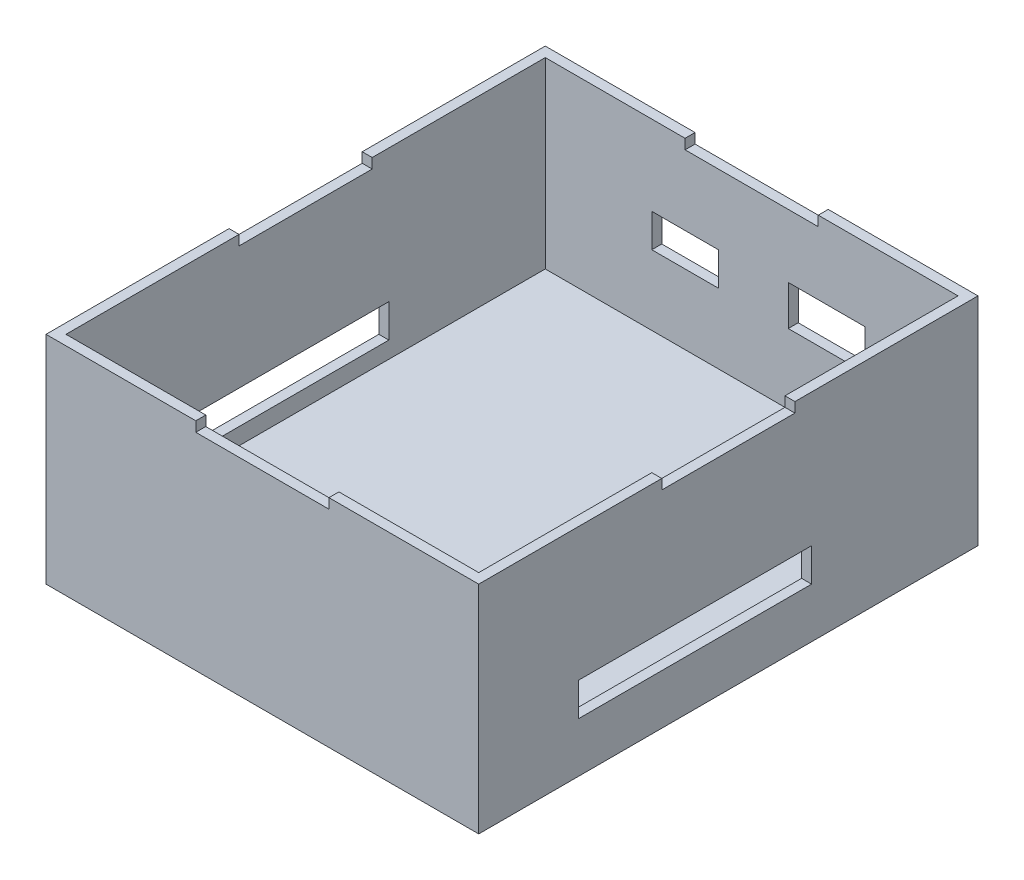
from build123d import *

# Parameters (mm, degrees)
ESBO_O1_W                = 130
ESBO_O1_H                = 65
RESSALTO_EXTRUS_O1_DEPTH = 150
ESBO_O2_W                = 70
ESBO_O2_H                = 10
CORTE_EXTRUS_O1_DEPTH    = 131
ESBO_O3_W                = 40
ESBO_O3_H                = 3
CORTE_EXTRUS_O2_DEPTH    = 131
ESBO_O4_W                = 40
ESBO_O4_H                = 3
CORTE_EXTRUS_O3_DEPTH    = 151
ESBO_O5_R                = 7.5
ESBO_O5_W                = 20
ESBO_O5_H                = 10
CORTE_EXTRUS_O4_DEPTH    = 141
ESBO_O6_W                = 124
ESBO_O6_H                = 144
CORTE_EXTRUS_O5_DEPTH    = 55
ESBO_O9_W                = 23
ESBO_O9_H                = 12
CORTE_EXTRUS_O6_DEPTH    = 3


with BuildPart() as part:
    # Esboço1 → Ressalto-extrusão1 (new body)
    with BuildSketch(Plane.XY):
        with Locations((12.060242954, 8.983357453)):
            Rectangle(ESBO_O1_W, ESBO_O1_H)
    extrude(amount=RESSALTO_EXTRUS_O1_DEPTH)

    # Esboço2 → Corte-extrusão1 (cut, through all)
    with BuildSketch(Plane.ZY.offset(52.939757046)):
        with Locations((85, -3.516642547)):
            Rectangle(ESBO_O2_W, ESBO_O2_H)
    extrude(amount=-CORTE_EXTRUS_O1_DEPTH, mode=Mode.SUBTRACT)

    # Esboço3 → Corte-extrusão2 (cut, through all)
    with BuildSketch(Plane.ZY.offset(52.939757046)):
        with Locations((75, 39.983357453)):
            Rectangle(ESBO_O3_W, ESBO_O3_H)
    extrude(amount=-CORTE_EXTRUS_O2_DEPTH, mode=Mode.SUBTRACT)

    # Esboço4 → Corte-extrusão3 (cut, through all)
    with BuildSketch(Plane(origin=(0, 0, 0), x_dir=(-1, 0, 0), z_dir=(0, 0, -1))):
        with Locations((-12.060242954, 39.983357453)):
            Rectangle(ESBO_O4_W, ESBO_O4_H)
    extrude(amount=-CORTE_EXTRUS_O3_DEPTH, mode=Mode.SUBTRACT)

    # Esboço5 → Corte-extrusão4 (cut)
    with BuildSketch(Plane(origin=(0, 0, 0), x_dir=(-1, 0, 0), z_dir=(0, 0, -1))):
        with Locations((-57.060242954, 7.483357453)):
            Circle(ESBO_O5_R)
        with Locations((7.939757046, 12.483357453)):
            Rectangle(ESBO_O5_W, ESBO_O5_H)
    extrude(amount=-CORTE_EXTRUS_O4_DEPTH, mode=Mode.SUBTRACT)

    # Esboço6 → Corte-extrusão5 (cut)
    with BuildSketch(Plane(origin=(0, 41.483357453, 0), x_dir=(1, 0, 0), z_dir=(0, 1, 0))):
        with Locations((12.060242954, -75)):
            Rectangle(ESBO_O6_W, ESBO_O6_H)
    extrude(amount=-CORTE_EXTRUS_O5_DEPTH, mode=Mode.SUBTRACT)

    # Esboço9 → Corte-extrusão6 (cut)
    with BuildSketch(Plane(origin=(0, 0, 0), x_dir=(-1, 0, 0), z_dir=(0, 0, -1))):
        with Locations((-34.560242954, 13.483357453)):
            Rectangle(ESBO_O9_W, ESBO_O9_H)
    extrude(amount=-CORTE_EXTRUS_O6_DEPTH, mode=Mode.SUBTRACT)


solid = part.part
